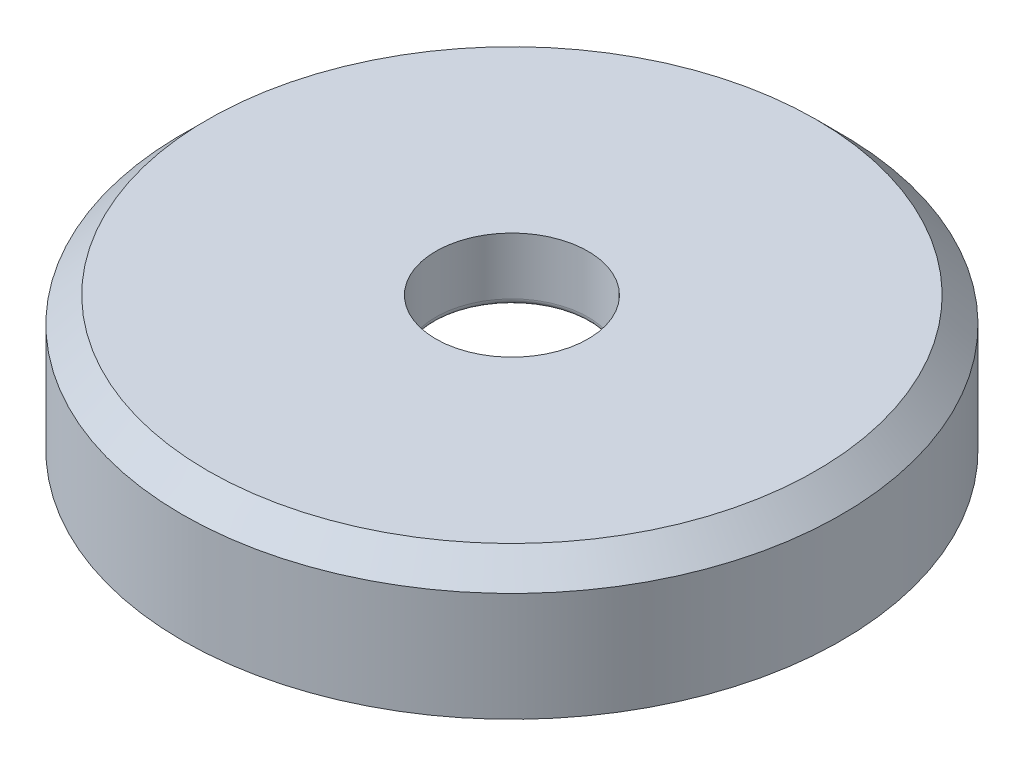
from build123d import *

# Parameters (mm, degrees)
SKETCH1_R           = 13
BOSS_EXTRUDE1_DEPTH = 2.8
SKETCH2_R           = 13
SKETCH2_R_2         = 3
BOSS_EXTRUDE2_DEPTH = 2.5
CHAMFER1_SIZE       = 1
FILLET1_R           = 0.25


with BuildPart() as part:
    # Sketch1 → Boss-Extrude1 (new body)
    with BuildSketch(Plane(origin=(0, 0, 0), x_dir=(1, 0, 0), z_dir=(0, 1, 0))):
        Circle(SKETCH1_R)
        Polygon((0, -9.959292144), (8.625, -4.979646072), (8.625, 4.979646072), (0, 9.959292144), (-8.625, 4.979646072), (-8.625, -4.979646072), align=None, mode=Mode.SUBTRACT)
    extrude(amount=BOSS_EXTRUDE1_DEPTH)

    # Sketch2 → Boss-Extrude2 (add)
    with BuildSketch(Plane(origin=(0, 2.8, 0), x_dir=(1, 0, 0), z_dir=(0, 1, 0))):
        Circle(SKETCH2_R)
        Circle(SKETCH2_R_2, mode=Mode.SUBTRACT)
    extrude(amount=BOSS_EXTRUDE2_DEPTH)

    # Chamfer1
    chamfer1_edges = [part.edges().sort_by_distance(p)[0] for p in [
        (-13, 5.3, 0),
    ]]
    chamfer(chamfer1_edges, length=CHAMFER1_SIZE)

    # Fillet1
    fillet1_edges = [part.edges().sort_by_distance(p)[0] for p in [
        (-3, 2.8, 0),
    ]]
    fillet(fillet1_edges, radius=FILLET1_R)


solid = part.part
